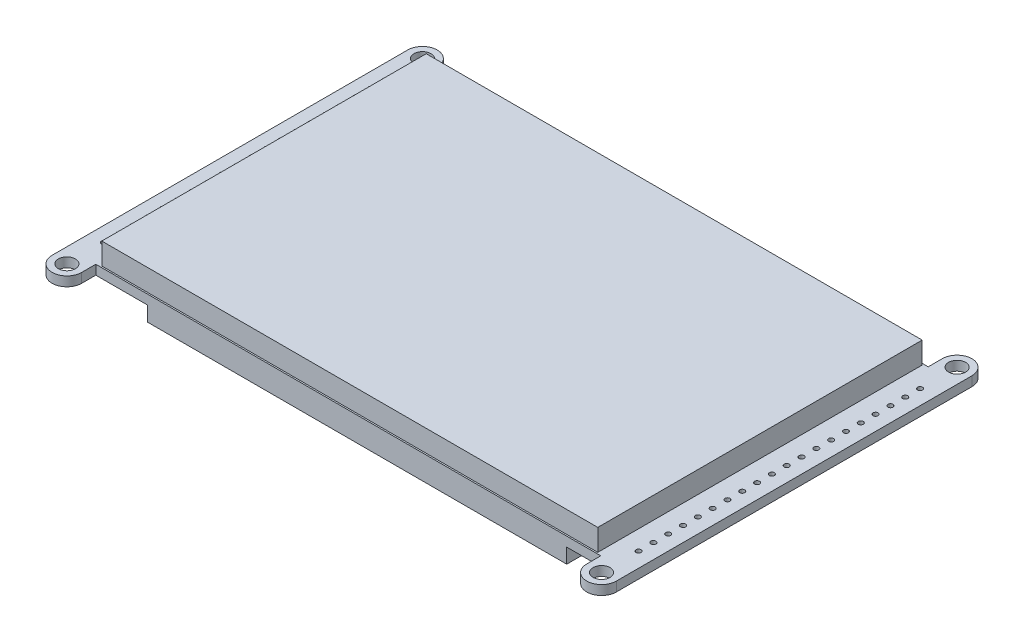
from build123d import *

# Parameters (mm, degrees)
SKETCH1_R           = 1.4605
SKETCH1_R_2         = 0.4318
SKETCH1_W           = 85.0392
SKETCH1_H           = 55.626
BOSS_EXTRUDE1_DEPTH = 1.6256
SKETCH1_2_W         = 85.0392
SKETCH1_2_H         = 55.626
BOSS_EXTRUDE2_DEPTH = 5.334
SKETCH2_W           = 71.8566
SKETCH2_H           = 56.134
BOSS_EXTRUDE3_DEPTH = 2.54


with BuildPart() as part:
    # Sketch1 → Boss-Extrude1 (new body)
    with BuildSketch(Plane(origin=(0, 0, 0), x_dir=(1, 0, 0), z_dir=(0, 1, 0))):
        with BuildLine():
            Line((43.2943, 28.067), (-43.2943, 28.067))
            Line((-43.2943, 28.067), (-43.2943, 30.48))
            ThreePointArc((-43.2943, 30.48), (-45.8343, 33.02), (-48.3743, 30.48))
            Line((-48.3743, 30.48), (-48.3743, -30.48))
            ThreePointArc((-48.3743, -30.48), (-45.8343, -33.02), (-43.2943, -30.48))
            Line((-43.2943, -30.48), (-43.2943, -28.067))
            Line((-43.2943, -28.067), (43.2943, -28.067))
            Line((43.2943, -28.067), (43.2943, -30.48))
            ThreePointArc((43.2943, -30.48), (45.8343, -33.02), (48.3743, -30.48))
            Line((48.3743, -30.48), (48.3743, 30.48))
            ThreePointArc((48.3743, 30.48), (45.8343, 33.02), (43.2943, 30.48))
            Line((43.2943, 30.48), (43.2943, 28.067))
        make_face()
        with Locations((-45.8343, 30.48)):
            Circle(SKETCH1_R, mode=Mode.SUBTRACT)
        with Locations((-45.8343, -30.48)):
            Circle(SKETCH1_R, mode=Mode.SUBTRACT)
        with Locations((45.8343, -30.48)):
            Circle(SKETCH1_R, mode=Mode.SUBTRACT)
        with Locations((45.8343, 30.48)):
            Circle(SKETCH1_R, mode=Mode.SUBTRACT)
        with Locations((-45.8343, 24.13)):
            Circle(SKETCH1_R_2, mode=Mode.SUBTRACT)
        with Locations((-45.8343, 21.59)):
            Circle(SKETCH1_R_2, mode=Mode.SUBTRACT)
        with Locations((-45.8343, 19.05)):
            Circle(SKETCH1_R_2, mode=Mode.SUBTRACT)
        with Locations((-45.8343, 16.51)):
            Circle(SKETCH1_R_2, mode=Mode.SUBTRACT)
        with Locations((-45.8343, 13.97)):
            Circle(SKETCH1_R_2, mode=Mode.SUBTRACT)
        with Locations((-45.8343, 11.43)):
            Circle(SKETCH1_R_2, mode=Mode.SUBTRACT)
        with Locations((-45.8343, 8.89)):
            Circle(SKETCH1_R_2, mode=Mode.SUBTRACT)
        with Locations((-45.8343, 6.35)):
            Circle(SKETCH1_R_2, mode=Mode.SUBTRACT)
        with Locations((-45.8343, 3.81)):
            Circle(SKETCH1_R_2, mode=Mode.SUBTRACT)
        with Locations((-45.8343, 1.27)):
            Circle(SKETCH1_R_2, mode=Mode.SUBTRACT)
        with Locations((-45.8343, -1.27)):
            Circle(SKETCH1_R_2, mode=Mode.SUBTRACT)
        with Locations((-45.8343, -3.81)):
            Circle(SKETCH1_R_2, mode=Mode.SUBTRACT)
        with Locations((-45.8343, -6.35)):
            Circle(SKETCH1_R_2, mode=Mode.SUBTRACT)
        with Locations((-45.8343, -8.89)):
            Circle(SKETCH1_R_2, mode=Mode.SUBTRACT)
        with Locations((-45.8343, -11.43)):
            Circle(SKETCH1_R_2, mode=Mode.SUBTRACT)
        with Locations((-45.8343, -13.97)):
            Circle(SKETCH1_R_2, mode=Mode.SUBTRACT)
        with Locations((-45.8343, -16.51)):
            Circle(SKETCH1_R_2, mode=Mode.SUBTRACT)
        with Locations((-45.8343, -19.05)):
            Circle(SKETCH1_R_2, mode=Mode.SUBTRACT)
        with Locations((-45.8343, -21.59)):
            Circle(SKETCH1_R_2, mode=Mode.SUBTRACT)
        with Locations((-45.8343, -24.13)):
            Circle(SKETCH1_R_2, mode=Mode.SUBTRACT)
        with Locations((45.8343, -24.13)):
            Circle(SKETCH1_R_2, mode=Mode.SUBTRACT)
        with Locations((45.8343, -21.59)):
            Circle(SKETCH1_R_2, mode=Mode.SUBTRACT)
        with Locations((45.8343, -19.05)):
            Circle(SKETCH1_R_2, mode=Mode.SUBTRACT)
        with Locations((45.8343, -16.51)):
            Circle(SKETCH1_R_2, mode=Mode.SUBTRACT)
        with Locations((45.8343, -13.97)):
            Circle(SKETCH1_R_2, mode=Mode.SUBTRACT)
        with Locations((45.8343, -11.43)):
            Circle(SKETCH1_R_2, mode=Mode.SUBTRACT)
        with Locations((45.8343, -8.89)):
            Circle(SKETCH1_R_2, mode=Mode.SUBTRACT)
        with Locations((45.8343, -6.35)):
            Circle(SKETCH1_R_2, mode=Mode.SUBTRACT)
        with Locations((45.8343, -3.81)):
            Circle(SKETCH1_R_2, mode=Mode.SUBTRACT)
        with Locations((45.8343, -1.27)):
            Circle(SKETCH1_R_2, mode=Mode.SUBTRACT)
        with Locations((45.8343, 1.27)):
            Circle(SKETCH1_R_2, mode=Mode.SUBTRACT)
        with Locations((45.8343, 3.81)):
            Circle(SKETCH1_R_2, mode=Mode.SUBTRACT)
        with Locations((45.8343, 6.35)):
            Circle(SKETCH1_R_2, mode=Mode.SUBTRACT)
        with Locations((45.8343, 8.89)):
            Circle(SKETCH1_R_2, mode=Mode.SUBTRACT)
        with Locations((45.8343, 11.43)):
            Circle(SKETCH1_R_2, mode=Mode.SUBTRACT)
        with Locations((45.8343, 13.97)):
            Circle(SKETCH1_R_2, mode=Mode.SUBTRACT)
        with Locations((45.8343, 16.51)):
            Circle(SKETCH1_R_2, mode=Mode.SUBTRACT)
        with Locations((45.8343, 19.05)):
            Circle(SKETCH1_R_2, mode=Mode.SUBTRACT)
        with Locations((45.8343, 21.59)):
            Circle(SKETCH1_R_2, mode=Mode.SUBTRACT)
        with Locations((45.8343, 24.13)):
            Circle(SKETCH1_R_2, mode=Mode.SUBTRACT)
        Rectangle(SKETCH1_W, SKETCH1_H, mode=Mode.SUBTRACT)
    extrude(amount=BOSS_EXTRUDE1_DEPTH)

    # Sketch1_2 → Boss-Extrude2 (add)
    with BuildSketch(Plane(origin=(0, 0, 0), x_dir=(1, 0, 0), z_dir=(0, 1, 0))):
        Rectangle(SKETCH1_2_W, SKETCH1_2_H)
    extrude(amount=BOSS_EXTRUDE2_DEPTH)

    # Sketch2 → Boss-Extrude3 (add)
    with BuildSketch(Plane.XZ):
        with Locations((1.524, 0)):
            Rectangle(SKETCH2_W, SKETCH2_H)
    extrude(amount=BOSS_EXTRUDE3_DEPTH)


solid = part.part
